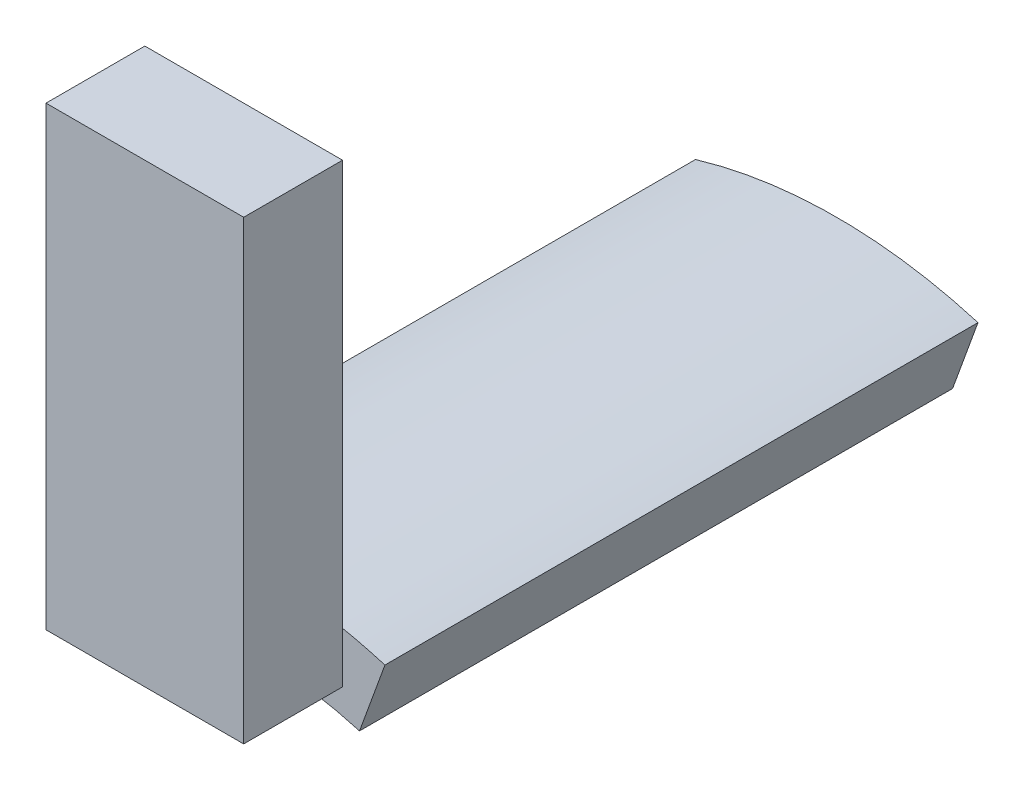
from build123d import *

# Parameters (mm, degrees)
BASE_EXTRUSION_DEPTH = 6
ESQUISSE2_W          = 2
ESQUISSE2_H          = 4.614800239
BOSS_EXTRU_1_DEPTH   = 1


with BuildPart() as part:
    # Esquisse1 → Base-Extrusion (new body)
    with BuildSketch(Plane.XY):
        with BuildLine():
            Line((-1.429070273, 4.791425482), (-1.172025132, 4.085199761))
            ThreePointArc((-1.172025132, 4.085199761), (0, 4.25), (1.172025132, 4.085199761))
            Line((1.172025132, 4.085199761), (1.429070273, 4.791425482))
            ThreePointArc((1.429070273, 4.791425482), (0, 5), (-1.429070273, 4.791425482))
        make_face()
    extrude(amount=BASE_EXTRUSION_DEPTH)

    # Esquisse2 → Boss.-Extru.1 (add)
    with BuildSketch(Plane.XY.offset(6)):
        with Locations((0, 6.69259988)):
            Rectangle(ESQUISSE2_W, ESQUISSE2_H)
    extrude(amount=BOSS_EXTRU_1_DEPTH)


solid = part.part
